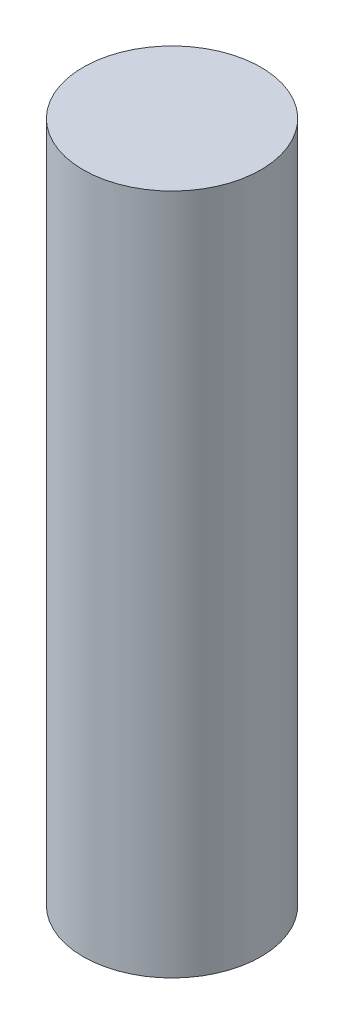
from build123d import *

# Parameters (mm, degrees)
SKETCH1_R           = 9
BOSS_EXTRUDE1_DEPTH = 69


with BuildPart() as part:
    # Sketch1 → Boss-Extrude1 (new body)
    with BuildSketch(Plane(origin=(0, 0, 0), x_dir=(1, 0, 0), z_dir=(0, 1, 0))):
        Circle(SKETCH1_R)
    extrude(amount=BOSS_EXTRUDE1_DEPTH)


solid = part.part
